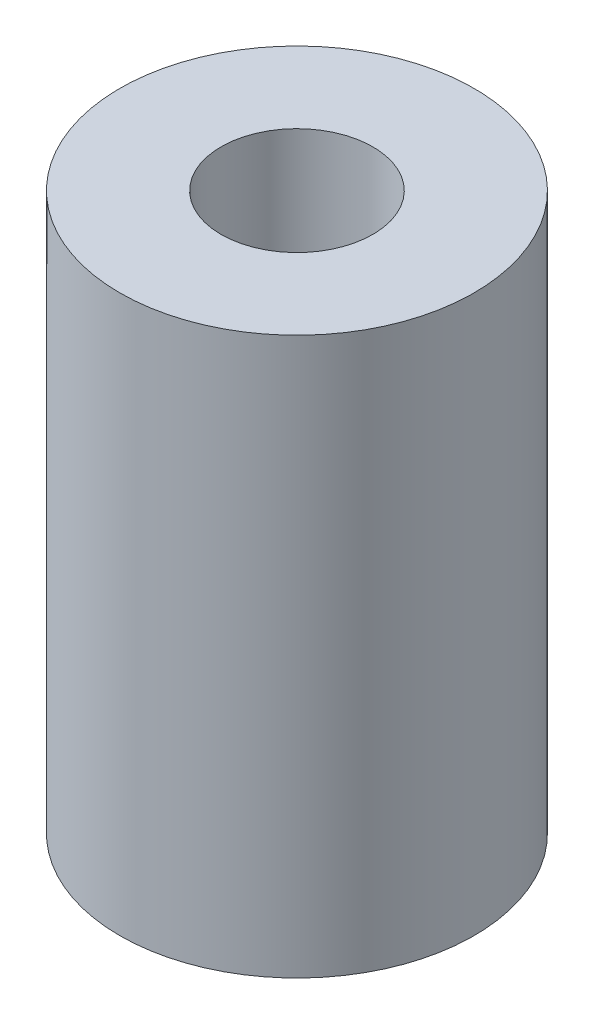
from build123d import *

# Parameters (mm, degrees)
SKETCH1_R           = 7
BOSS_EXTRUDE1_DEPTH = 11
SKETCH2_R           = 3
CUT_EXTRUDE1_DEPTH  = 11
SKETCH3_R           = 4
CUT_EXTRUDE2_DEPTH  = 11


with BuildPart() as part:
    # Sketch1 → Boss-Extrude1 (new body, symmetric)
    with BuildSketch(Plane(origin=(0, 0, 0), x_dir=(1, 0, 0), z_dir=(0, 1, 0))):
        Circle(SKETCH1_R)
    extrude(amount=BOSS_EXTRUDE1_DEPTH, both=True)

    # Sketch2 → Cut-Extrude1 (cut)
    with BuildSketch(Plane(origin=(0, 11, 0), x_dir=(1, 0, 0), z_dir=(0, 1, 0))):
        Circle(SKETCH2_R)
    extrude(amount=-CUT_EXTRUDE1_DEPTH, mode=Mode.SUBTRACT)

    # Sketch3 → Cut-Extrude2 (cut)
    with BuildSketch(Plane.XZ.offset(11)):
        Circle(SKETCH3_R)
    extrude(amount=-CUT_EXTRUDE2_DEPTH, mode=Mode.SUBTRACT)


solid = part.part
